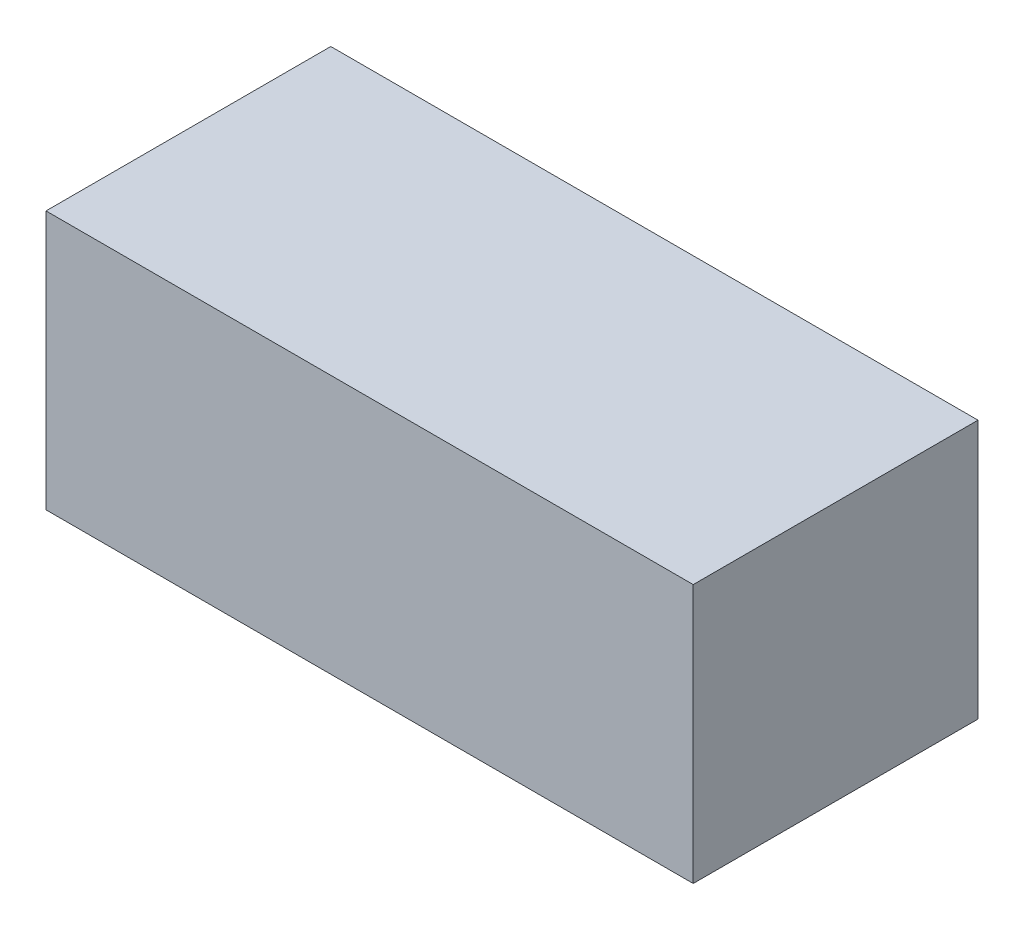
from build123d import *

# Parameters (mm, degrees)
SKETCH1_W      = 500
SKETCH1_H      = 220
EXTRUDE1_DEPTH = 200


with BuildPart() as part:
    # Sketch1 → Extrude1 (new body)
    with BuildSketch(Plane(origin=(0, 0, 0), x_dir=(1, 0, 0), z_dir=(0, 1, 0))):
        with Locations((-250, 110)):
            Rectangle(SKETCH1_W, SKETCH1_H)
    extrude(amount=EXTRUDE1_DEPTH)


solid = part.part
